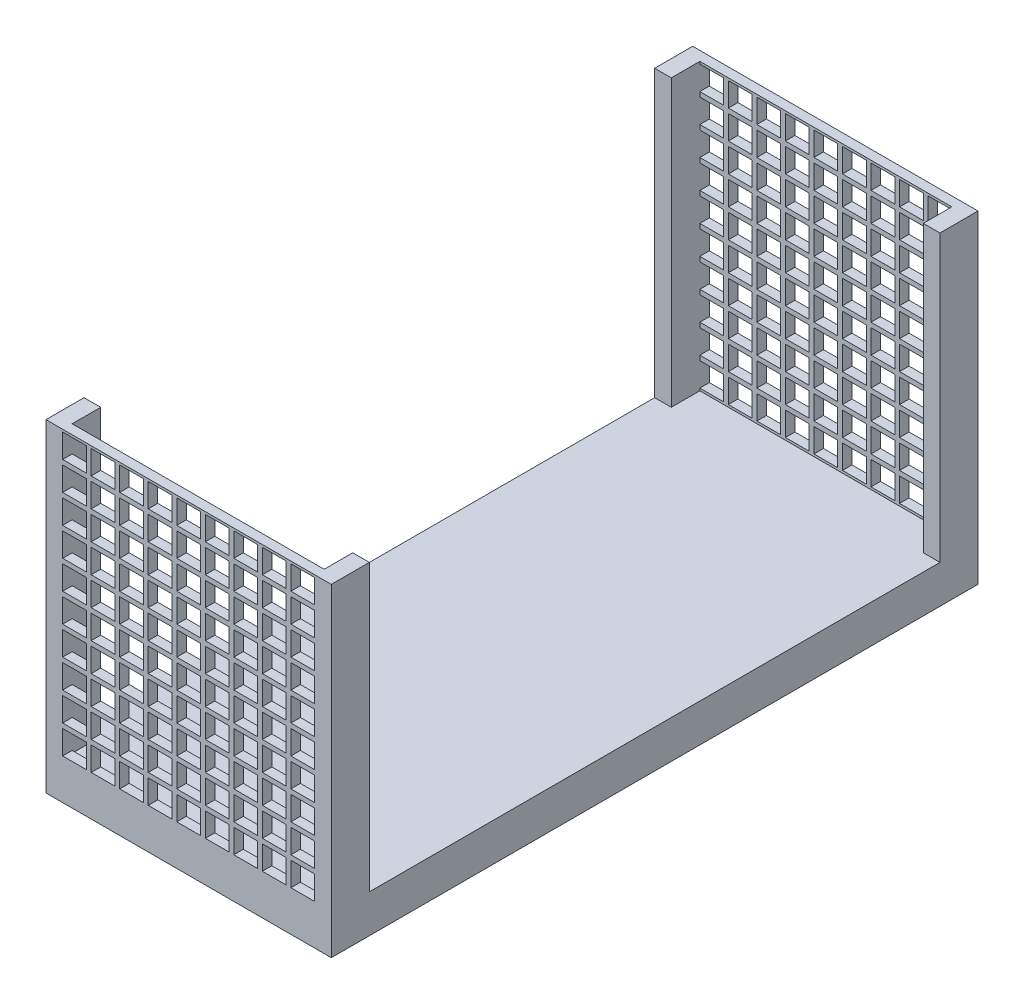
from build123d import *

# Parameters (mm, degrees)
SKETCH1_W            = 15
SKETCH1_H            = 17
BOSS_EXTRUDE1_DEPTH  = 34
CUT_EXTRUDE1_REACH   = 17
SKETCH2_W            = 30
SKETCH2_H            = 15
CUT_EXTRUDE4_START   = -2
SKETCH5_W            = 13.25
SKETCH5_H            = 15
CUT_EXTRUDE4_DEPTH   = 1.5
CUT_EXTRUDE2_START   = -2
SKETCH3_W            = 13.25
SKETCH3_H            = 15
CUT_EXTRUDE2_DEPTH   = 1.5
CUT_EXTRUDE5_START   = -0.5
SKETCH6_W            = 1.25
SKETCH6_H            = 1.25
CUT_EXTRUDE5_DEPTH   = 35
LPATTERN1_COUNT      = 9
LPATTERN1_PITCH      = 1.5
LPATTERN1_COUNT_DIR2 = 10
LPATTERN1_PITCH_DIR2 = 1.5


with BuildPart() as part:
    # Sketch1 → Boss-Extrude1 (new body)
    with BuildSketch(Plane.XY):
        Rectangle(SKETCH1_W, SKETCH1_H)
    extrude(amount=BOSS_EXTRUDE1_DEPTH)

    # Sketch2 → Cut-Extrude1 (cut, up to next)
    with BuildSketch(Plane(origin=(7.5, 0, 0), x_dir=(0, 0, -1), z_dir=(1, 0, 0)), mode=Mode.PRIVATE) as cut_extrude1_sk1:
        with Locations((-17, 1)):
            Rectangle(SKETCH2_W, SKETCH2_H)
    cut_extrude1_tool1 = extrude(cut_extrude1_sk1.sketch, amount=-CUT_EXTRUDE1_REACH, mode=Mode.PRIVATE) & part.part
    add(cut_extrude1_tool1.solids().sort_by_distance((7.5, 1, 17))[0], mode=Mode.SUBTRACT)

    # Sketch5 → Cut-Extrude4 (cut)
    with BuildSketch(Plane(origin=(0, 0, 0), x_dir=(-1, 0, 0), z_dir=(0, 0, -1)).offset(CUT_EXTRUDE4_START)):
        with Locations((0, 1)):
            Rectangle(SKETCH5_W, SKETCH5_H)
    extrude(amount=CUT_EXTRUDE4_DEPTH, mode=Mode.SUBTRACT)

    # Sketch3 → Cut-Extrude2 (cut)
    with BuildSketch(Plane.XY.offset(34).offset(CUT_EXTRUDE2_START)):
        with Locations((0, 1)):
            Rectangle(SKETCH3_W, SKETCH3_H)
    extrude(amount=CUT_EXTRUDE2_DEPTH, mode=Mode.SUBTRACT)

    # Sketch6 → Cut-Extrude5 (cut, through all)
    with BuildSketch(Plane(origin=(0, 0, 33.5), x_dir=(-1, 0, 0), z_dir=(0, 0, -1)).offset(CUT_EXTRUDE5_START)):
        with Locations((-6, 7.75)):
            Rectangle(SKETCH6_W, SKETCH6_H)
    cut_extrude5 = extrude(amount=CUT_EXTRUDE5_DEPTH, mode=Mode.SUBTRACT)

    # LPattern1: Cut-Extrude5 9 × 10
    with Locations(*[(-i * LPATTERN1_PITCH, -j * LPATTERN1_PITCH_DIR2, 0) for i in range(LPATTERN1_COUNT) for j in range(LPATTERN1_COUNT_DIR2) if (i, j) != (0, 0)]):
        add(cut_extrude5, mode=Mode.SUBTRACT)


solid = part.part
